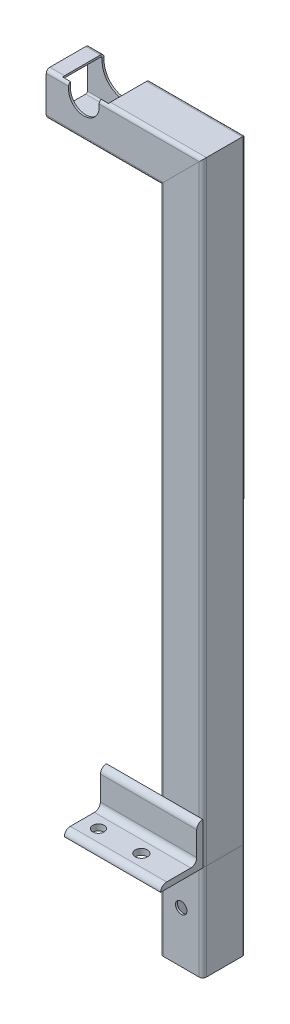
from build123d import *

# Parameters (mm, degrees)
STRUCTURAL_MEMBERMAIN_DEPTH                   = 1
STRUCTURAL_MEMBERMAIN_DEPTH_BACK              = 80
STRUCTURAL_MEMBERMAIN_2_DEPTH                 = 518.914422766
STRUCTURAL_MEMBERMAIN_3_DEPTH                 = 138.414422766
CUT_EXTRUDETOPRAILGUIDE_DEPTH                 = 589.881018463
CUT_EXTRUDETOPRAILGUIDE_DEPTH_BACK            = 589.881018463
STRUCTURAL_MEMBERANGLE_DEPTH                  = 80
SKETCH15_R                                    = 4.7625
SKETCH15_R_2                                  = 5.044092484
CUT_EXTRUDEMOUNTINGHOLES_DEPTH                = 591.981263583
CUT_EXTRUDEENLARGERAILGUIDE_DEPTH             = 591.981263583
CUT_EXTRUDEENLARGERAILGUIDE_DIRECTION_2_REACH = 592.981
SKETCH17_R                                    = 4.7625
CUT_EXTRUDE1_DEPTH                            = 590.696603268


with BuildPart() as part:
    # Sketch11 → Structural MemberMain (new, two sides)
    with BuildSketch(Plane(origin=(276.8375, 0, 0), x_dir=(-1, 0, 0), z_dir=(0, 1, 0))) as structural_membermain_sk:
        with BuildLine():
            Line((-14.9, 17.9), (14.9, 17.9))
            ThreePointArc((14.9, 17.9), (17.021320344, 17.021320344), (17.9, 14.9))
            Line((17.9, 14.9), (17.9, -14.9))
            ThreePointArc((17.9, -14.9), (17.021320344, -17.021320344), (14.9, -17.9))
            Line((14.9, -17.9), (-14.9, -17.9))
            ThreePointArc((-14.9, -17.9), (-17.021320344, -17.021320344), (-17.9, -14.9))
            Line((-17.9, -14.9), (-17.9, 14.9))
            ThreePointArc((-17.9, 14.9), (-17.021320344, 17.021320344), (-14.9, 17.9))
        make_face()
        with BuildLine():
            Line((-14.9, 16.3), (14.9, 16.3))
            ThreePointArc((14.9, 16.3), (15.889949494, 15.889949494), (16.3, 14.9))
            Line((16.3, 14.9), (16.3, -14.9))
            ThreePointArc((16.3, -14.9), (15.889949494, -15.889949494), (14.9, -16.3))
            Line((14.9, -16.3), (-14.9, -16.3))
            ThreePointArc((-14.9, -16.3), (-15.889949494, -15.889949494), (-16.3, -14.9))
            Line((-16.3, -14.9), (-16.3, 14.9))
            ThreePointArc((-16.3, 14.9), (-15.889949494, 15.889949494), (-14.9, 16.3))
        make_face(mode=Mode.SUBTRACT)
    extrude(amount=STRUCTURAL_MEMBERMAIN_DEPTH)
    extrude(structural_membermain_sk.sketch, amount=-STRUCTURAL_MEMBERMAIN_DEPTH_BACK)

    # Structural MemberMain mitre 1
    split(bisect_by=Plane(origin=(276.8375, 0, 0), x_dir=(1, 0, 0), z_dir=(0, -1, 0)), keep=Keep.TOP)

    # Sketch17 → Cut-Extrude1 (cut, through all)
    with BuildSketch(Plane.XY.offset(17.9)):
        with Locations((276.8375, -37.5)):
            Circle(SKETCH17_R)
    extrude(amount=-CUT_EXTRUDE1_DEPTH, mode=Mode.SUBTRACT)


with BuildPart() as body_2:
    # Sketch11 on segment 2 (carried to segment 2) → Structural MemberMain 2 (new body)
    with BuildSketch(Plane(origin=(276.8375, -1, 0), x_dir=(-1, 0, 0), z_dir=(0, 1, 0))):
        with BuildLine():
            Line((-14.9, 17.9), (14.9, 17.9))
            ThreePointArc((14.9, 17.9), (17.021320344, 17.021320344), (17.9, 14.9))
            Line((17.9, 14.9), (17.9, -14.9))
            ThreePointArc((17.9, -14.9), (17.021320344, -17.021320344), (14.9, -17.9))
            Line((14.9, -17.9), (-14.9, -17.9))
            ThreePointArc((-14.9, -17.9), (-17.021320344, -17.021320344), (-17.9, -14.9))
            Line((-17.9, -14.9), (-17.9, 14.9))
            ThreePointArc((-17.9, 14.9), (-17.021320344, 17.021320344), (-14.9, 17.9))
        make_face()
        with BuildLine():
            Line((-14.9, 16.3), (14.9, 16.3))
            ThreePointArc((14.9, 16.3), (15.889949494, 15.889949494), (16.3, 14.9))
            Line((16.3, 14.9), (16.3, -14.9))
            ThreePointArc((16.3, -14.9), (15.889949494, -15.889949494), (14.9, -16.3))
            Line((14.9, -16.3), (-14.9, -16.3))
            ThreePointArc((-14.9, -16.3), (-15.889949494, -15.889949494), (-16.3, -14.9))
            Line((-16.3, -14.9), (-16.3, 14.9))
            ThreePointArc((-16.3, 14.9), (-15.889949494, 15.889949494), (-14.9, 16.3))
        make_face(mode=Mode.SUBTRACT)
    extrude(amount=STRUCTURAL_MEMBERMAIN_2_DEPTH)

    # Structural MemberMain 2 mitre 1
    split(bisect_by=Plane(origin=(276.8375, 0, 0), x_dir=(-1, 0, 0), z_dir=(0, 1, 0)), keep=Keep.TOP)

    # Structural MemberMain 2 mitre 2
    split(bisect_by=Plane(origin=(276.8375, 491.6, 0), x_dir=(0.707106781, 0.707106781, 0), z_dir=(0.707106781, -0.707106781, 0)), keep=Keep.TOP)


with BuildPart() as body_3:
    # Sketch11 on segment 3 (carried to segment 3) → Structural MemberMain 3 (new body)
    with BuildSketch(Plane(origin=(303.151922766, 491.6, 0), x_dir=(0, -1, 0), z_dir=(-1, 0, 0))):
        with BuildLine():
            Line((-14.9, 17.9), (14.9, 17.9))
            ThreePointArc((14.9, 17.9), (17.021320344, 17.021320344), (17.9, 14.9))
            Line((17.9, 14.9), (17.9, -14.9))
            ThreePointArc((17.9, -14.9), (17.021320344, -17.021320344), (14.9, -17.9))
            Line((14.9, -17.9), (-14.9, -17.9))
            ThreePointArc((-14.9, -17.9), (-17.021320344, -17.021320344), (-17.9, -14.9))
            Line((-17.9, -14.9), (-17.9, 14.9))
            ThreePointArc((-17.9, 14.9), (-17.021320344, 17.021320344), (-14.9, 17.9))
        make_face()
        with BuildLine():
            Line((-14.9, 16.3), (14.9, 16.3))
            ThreePointArc((14.9, 16.3), (15.889949494, 15.889949494), (16.3, 14.9))
            Line((16.3, 14.9), (16.3, -14.9))
            ThreePointArc((16.3, -14.9), (15.889949494, -15.889949494), (14.9, -16.3))
            Line((14.9, -16.3), (-14.9, -16.3))
            ThreePointArc((-14.9, -16.3), (-15.889949494, -15.889949494), (-16.3, -14.9))
            Line((-16.3, -14.9), (-16.3, 14.9))
            ThreePointArc((-16.3, 14.9), (-15.889949494, 15.889949494), (-14.9, 16.3))
        make_face(mode=Mode.SUBTRACT)
    extrude(amount=STRUCTURAL_MEMBERMAIN_3_DEPTH)

    # Structural MemberMain 3 mitre 1
    split(bisect_by=Plane(origin=(276.8375, 491.6, 0), x_dir=(-0.707106781, -0.707106781, 0), z_dir=(-0.707106781, 0.707106781, 0)), keep=Keep.TOP)

    # Sketch12 → Cut-ExtrudeTopRailGuide (cut, two sides)
    with BuildSketch(Plane.XY) as cut_extrudetoprailguide_sk:
        with BuildLine():
            Line((183.3, 504.3), (183.3, 514.7))
            ThreePointArc((183.3, 514.7), (196, 527.4), (208.7, 514.7))
            Line((208.7, 514.7), (208.7, 504.3))
            ThreePointArc((208.7, 504.3), (196, 491.6), (183.3, 504.3))
        make_face()
    extrude(amount=CUT_EXTRUDETOPRAILGUIDE_DEPTH, mode=Mode.SUBTRACT)
    extrude(cut_extrudetoprailguide_sk.sketch, amount=-CUT_EXTRUDETOPRAILGUIDE_DEPTH_BACK, mode=Mode.SUBTRACT)

    # Sketch16 → Cut-ExtrudeEnlargeRailGuide (cut)
    with BuildSketch(Plane.XY):
        with BuildLine():
            Line((215.05, 504.3), (215.05, 514.7))
            ThreePointArc((215.05, 514.7), (196, 533.75), (176.95, 514.7))
            Line((176.95, 514.7), (176.95, 504.3))
            ThreePointArc((176.95, 504.3), (196, 485.25), (215.05, 504.3))
        make_face()
    extrude(amount=-CUT_EXTRUDEENLARGERAILGUIDE_DEPTH, mode=Mode.SUBTRACT)

    # Cut-ExtrudeEnlargeRailGuide direction 2: up to this face of the body (flat: up to its plane)
    cut_extrudeenlargerailguide_direction_2_end = Plane(body_3.part.faces().sort_by_distance((223.67987198, 491.462157452, 16.3))[0])
    # Sketch16 → Cut-ExtrudeEnlargeRailGuide direction 2 (cut, up to the picked face)
    with BuildSketch(Plane.XY, mode=Mode.PRIVATE) as cut_extrudeenlargerailguide_direction_2_sk1:
        with BuildLine():
            Line((215.05, 504.3), (215.05, 514.7))
            ThreePointArc((215.05, 514.7), (196, 533.75), (176.95, 514.7))
            Line((176.95, 514.7), (176.95, 504.3))
            ThreePointArc((176.95, 504.3), (196, 485.25), (215.05, 504.3))
        make_face()
    cut_extrudeenlargerailguide_direction_2_tool1 = split(extrude(cut_extrudeenlargerailguide_direction_2_sk1.sketch, amount=CUT_EXTRUDEENLARGERAILGUIDE_DIRECTION_2_REACH, mode=Mode.PRIVATE), bisect_by=cut_extrudeenlargerailguide_direction_2_end, keep=Keep.BOTH, mode=Mode.PRIVATE)
    add(cut_extrudeenlargerailguide_direction_2_tool1.solids().sort_by(Axis((196, 509.5, 0), (0, 0, 1)))[0], mode=Mode.SUBTRACT)


with BuildPart() as body_4:
    # Sketch14 → Structural MemberAngle (new body)
    with BuildSketch(Plane(origin=(214.7375, 0, 17.9), x_dir=(0, 1, 0), z_dir=(1, 0, 0))):
        with BuildLine():
            Line((0, 0), (0, 35))
            ThreePointArc((0, 35), (3.535533906, 33.535533906), (5, 30))
            Line((5, 30), (5, 10))
            ThreePointArc((5, 10), (6.464466094, 6.464466094), (10, 5))
            Line((10, 5), (30, 5))
            ThreePointArc((30, 5), (33.535533906, 3.535533906), (35, 0))
            Line((35, 0), (0, 0))
        make_face()
    extrude(amount=STRUCTURAL_MEMBERANGLE_DEPTH)

    # Sketch15 → Cut-ExtrudeMountingHoles (cut, through all)
    with BuildSketch(Plane(origin=(0, 0, 0), x_dir=(1, 0, 0), z_dir=(0, 1, 0))):
        with Locations(Location((228.1, -37.9, 0), (0, 0, 90))):
            Circle(SKETCH15_R)
        with Locations(Location((263.7, -37.9, 0), (0, 0, 90))):
            Circle(SKETCH15_R_2)
    extrude(amount=CUT_EXTRUDEMOUNTINGHOLES_DEPTH, mode=Mode.SUBTRACT)


solid = Compound([part.part, body_2.part, body_3.part, body_4.part])
